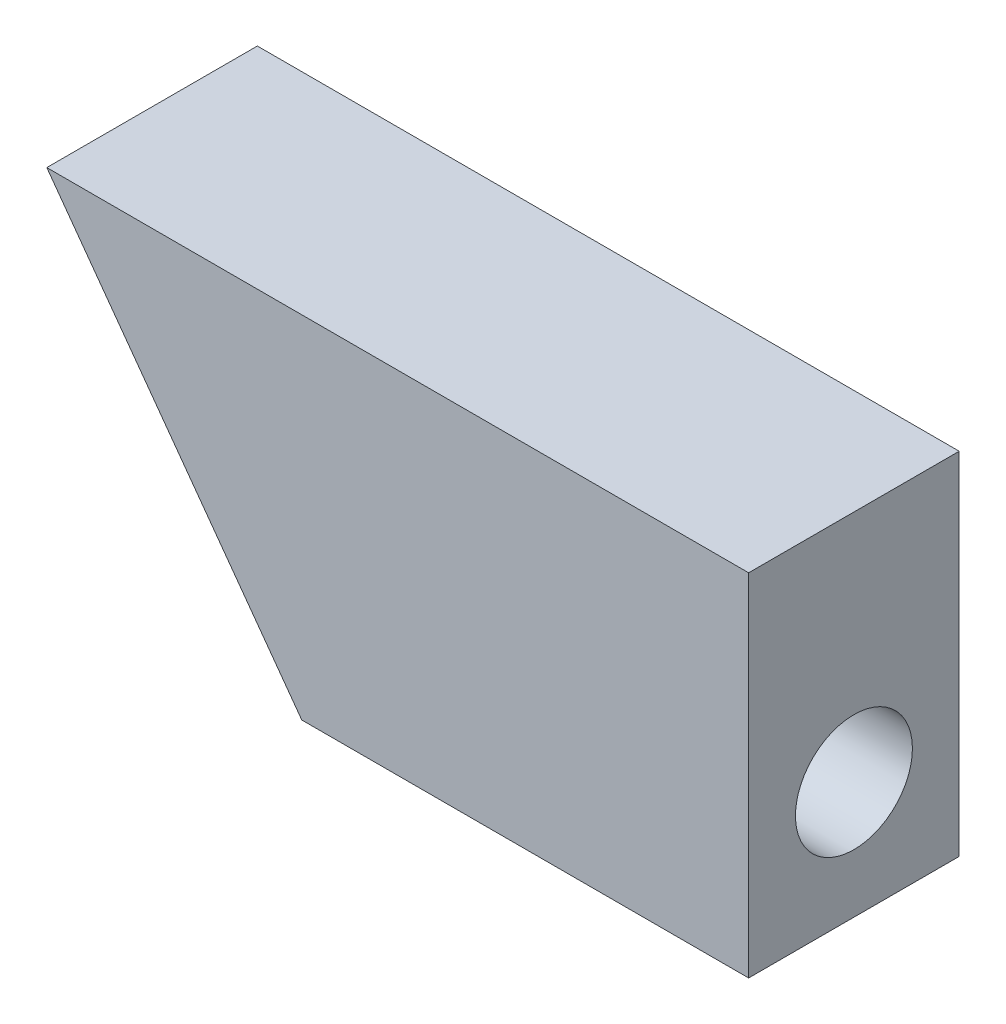
from build123d import *

# Parameters (mm, degrees)
EXTRUDE_1_DEPTH     = 9
SKETCH_2_R          = 2.5
CUT_EXTRUDE_1_DEPTH = 30


with BuildPart() as part:
    # 草图1 → 凸台-拉伸1 (new body)
    with BuildSketch(Plane.XY):
        Polygon((19.10186208, 0), (0, 0), (-10.89813792, 15), (19.10186208, 15), align=None)
    extrude(amount=EXTRUDE_1_DEPTH)

    # 草图2 → 切除-拉伸1 (cut)
    with BuildSketch(Plane(origin=(19.10186208, 0, 0), x_dir=(0, 0, -1), z_dir=(1, 0, 0))):
        with Locations((-4.5, 5)):
            Circle(SKETCH_2_R)
    extrude(amount=-CUT_EXTRUDE_1_DEPTH, mode=Mode.SUBTRACT)


solid = part.part
